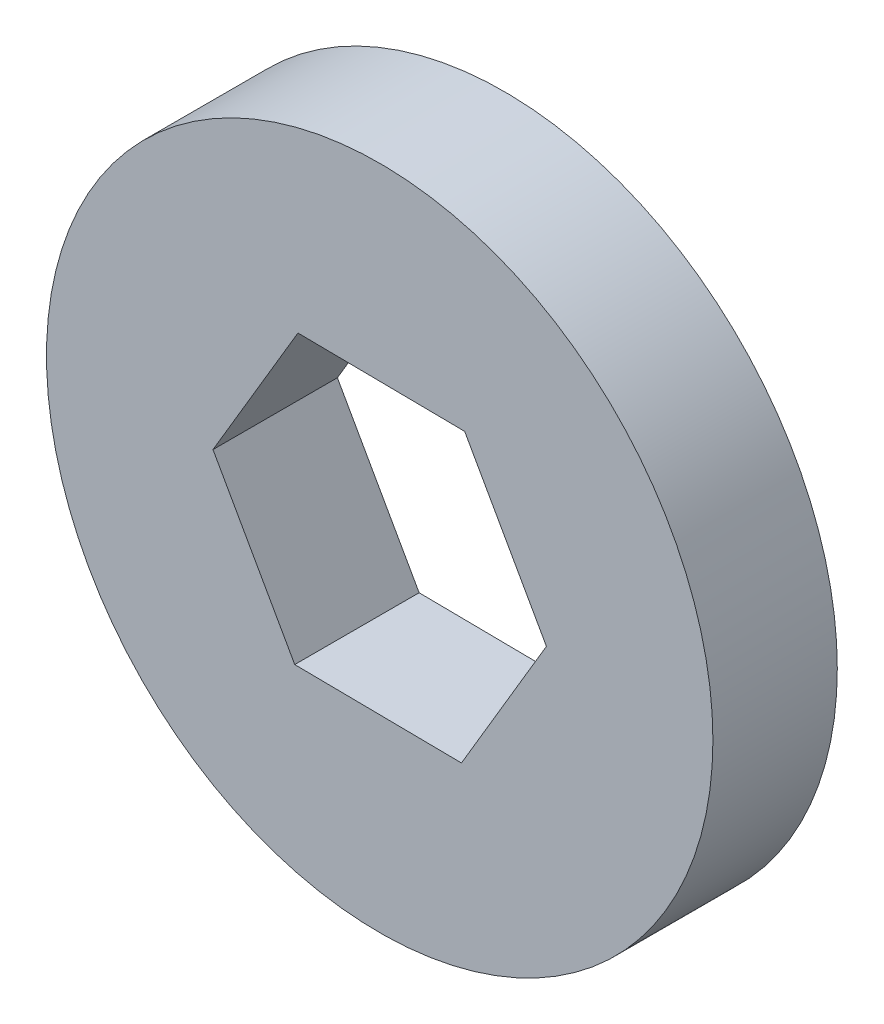
from build123d import *

# Parameters (mm, degrees)
CROQUIS1_R              = 15
SALIENTE_EXTRUIR1_DEPTH = 5.6


with BuildPart() as part:
    # Croquis1 → Saliente-Extruir1 (new body)
    with BuildSketch(Plane.XY):
        Circle(CROQUIS1_R)
        Polygon((3.679984632, -6.541486562), (7.505085857, -0.083783104), (3.825101225, 6.457703458), (-3.679984632, 6.541486562), (-7.505085857, 0.083783104), (-3.825101225, -6.457703458), align=None, mode=Mode.SUBTRACT)
    extrude(amount=SALIENTE_EXTRUIR1_DEPTH)


solid = part.part
